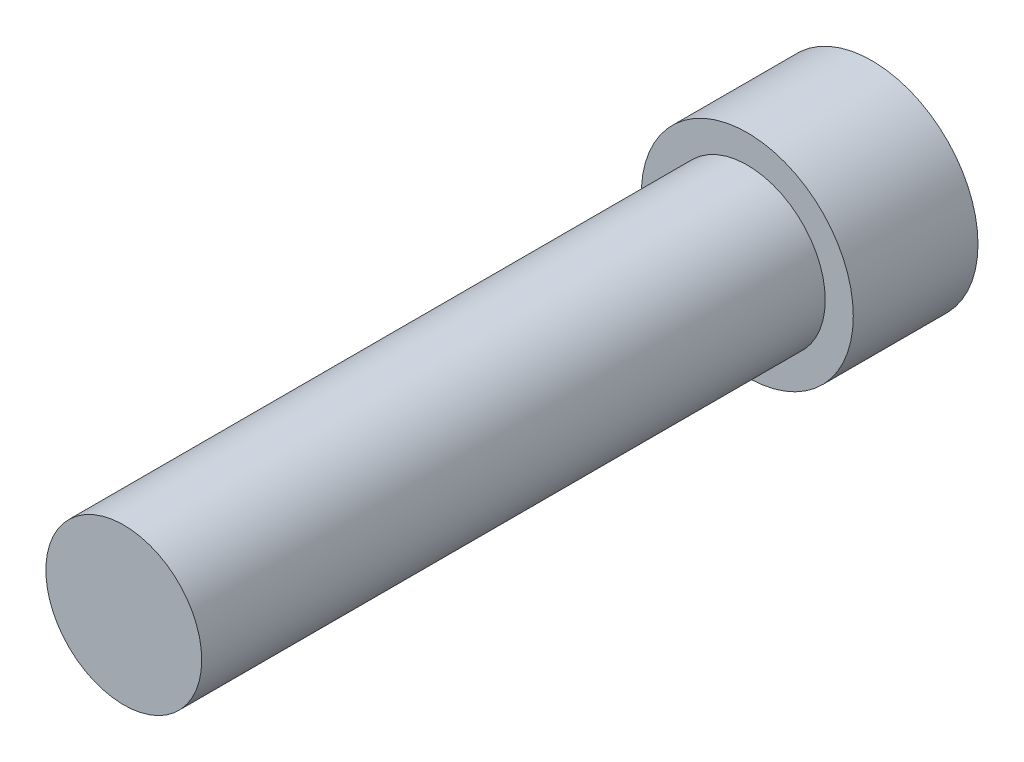
from build123d import *

# Parameters (mm, degrees)
SKETCH1_R           = 1.25
BOSS_EXTRUDE1_DEPTH = 12
SKETCH1_3_R         = 1.7
SKETCH1_3_R_2       = 1.25
BOSS_EXTRUDE2_DEPTH = 2
CUT_EXTRUDE1_DEPTH  = 2


with BuildPart() as part:
    # Sketch1 → Boss-Extrude1 (new body)
    with BuildSketch(Plane.XY):
        Circle(SKETCH1_R)
    extrude(amount=BOSS_EXTRUDE1_DEPTH)

    # Sketch1_3 → Boss-Extrude2 (add)
    with BuildSketch(Plane.XY):
        Circle(SKETCH1_3_R)
        Circle(SKETCH1_3_R_2, mode=Mode.SUBTRACT)
    extrude(amount=BOSS_EXTRUDE2_DEPTH)

    # Sketch3 → Cut-Extrude1 (cut)
    with BuildSketch(Plane(origin=(0, 0, 0), x_dir=(-1, 0, 0), z_dir=(0, 0, -1))):
        Polygon((0.988114182, -0.597464389), (1.01147643, 0.556999789), (0.023362248, 1.154464178), (-0.988114182, 0.597464389), (-1.01147643, -0.556999789), (-0.023362248, -1.154464178), align=None)
    extrude(amount=-CUT_EXTRUDE1_DEPTH, mode=Mode.SUBTRACT)


solid = part.part
